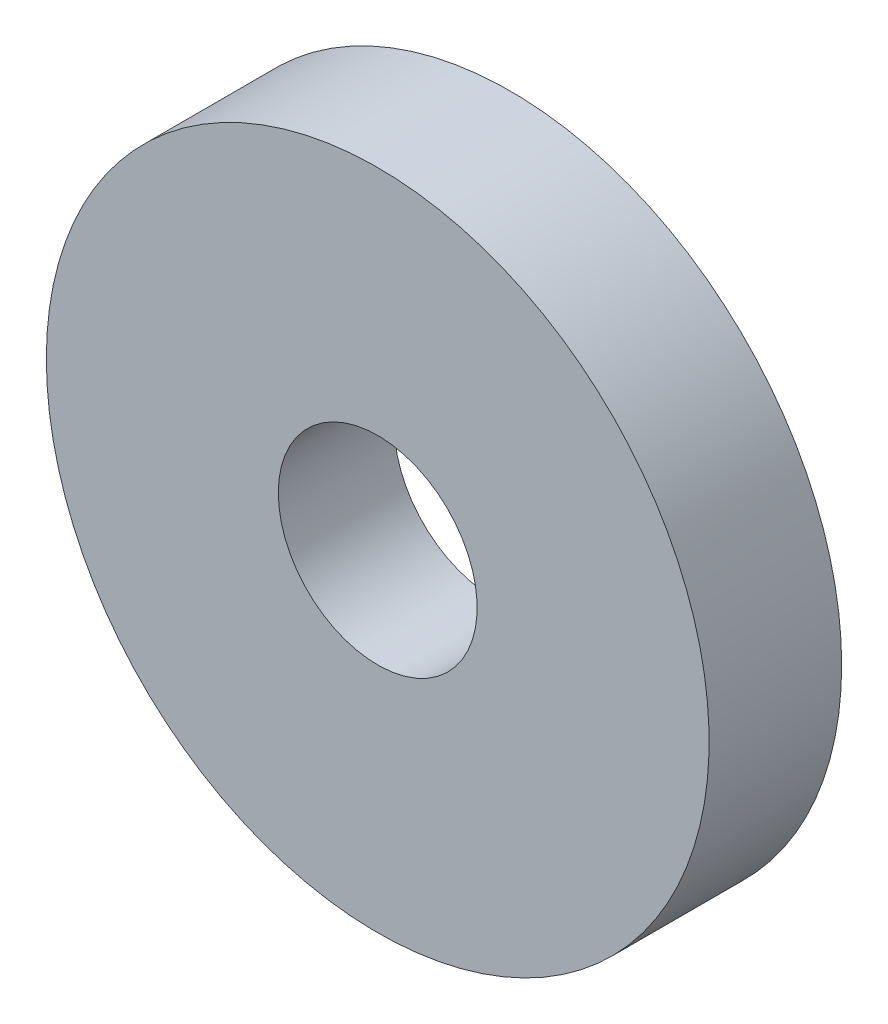
from build123d import *

# Parameters (mm, degrees)
SKETCH_1_R      = 20
SKETCH_1_R_2    = 7.9
EXTRUDE_1_DEPTH = 1
SKETCH_2_R      = 20
SKETCH_2_R_2    = 6
EXTRUDE_2_DEPTH = 7


with BuildPart() as part:
    # Эскиз1 → Бобышка-Вытянуть1 (new body)
    with BuildSketch(Plane.XY):
        Circle(SKETCH_1_R)
        Circle(SKETCH_1_R_2, mode=Mode.SUBTRACT)
    extrude(amount=EXTRUDE_1_DEPTH)

    # Эскиз2 → Бобышка-Вытянуть2 (add)
    with BuildSketch(Plane.XY.offset(1)):
        Circle(SKETCH_2_R)
        Circle(SKETCH_2_R_2, mode=Mode.SUBTRACT)
    extrude(amount=EXTRUDE_2_DEPTH)


solid = part.part
